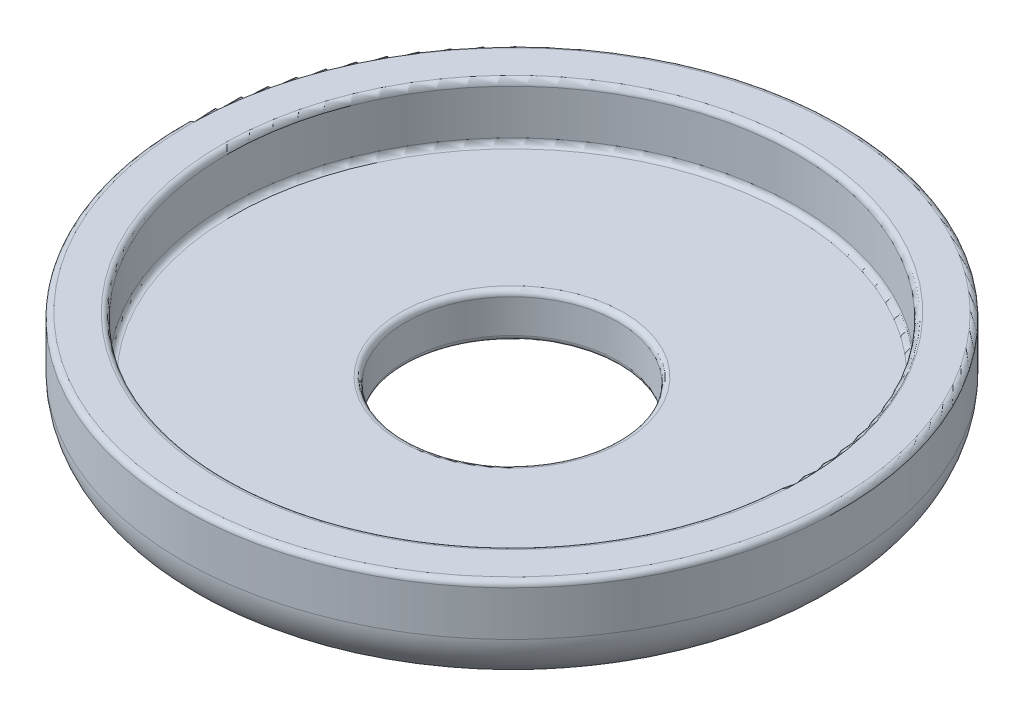
from build123d import *


with BuildPart() as part:
    # Sketch1 → Revolve1 (revolve)
    with BuildSketch(Plane.XY):
        with BuildLine():
            Line((5, 0), (12.5, 0))
            ThreePointArc((12.5, 0), (14.090990258, 0.659009742), (14.75, 2.25))
            Line((14.75, 2.25), (14.75, 4.25))
            ThreePointArc((14.75, 4.25), (14.676776695, 4.426776695), (14.5, 4.5))
            Line((14.5, 4.5), (13, 4.5))
            ThreePointArc((13, 4.5), (12.823223305, 4.426776695), (12.75, 4.25))
            Line((12.75, 4.25), (12.75, 2.25))
            ThreePointArc((12.75, 2.25), (12.676776695, 2.073223305), (12.5, 2))
            Line((12.5, 2), (5, 2))
            ThreePointArc((5, 2), (4.823223305, 1.926776695), (4.75, 1.75))
            Line((4.75, 1.75), (4.75, 0.25))
            ThreePointArc((4.75, 0.25), (4.823223305, 0.073223305), (5, 0))
        make_face()
    revolve(axis=Axis((0, 0, 0), (0, 1, 0)))


solid = part.part
